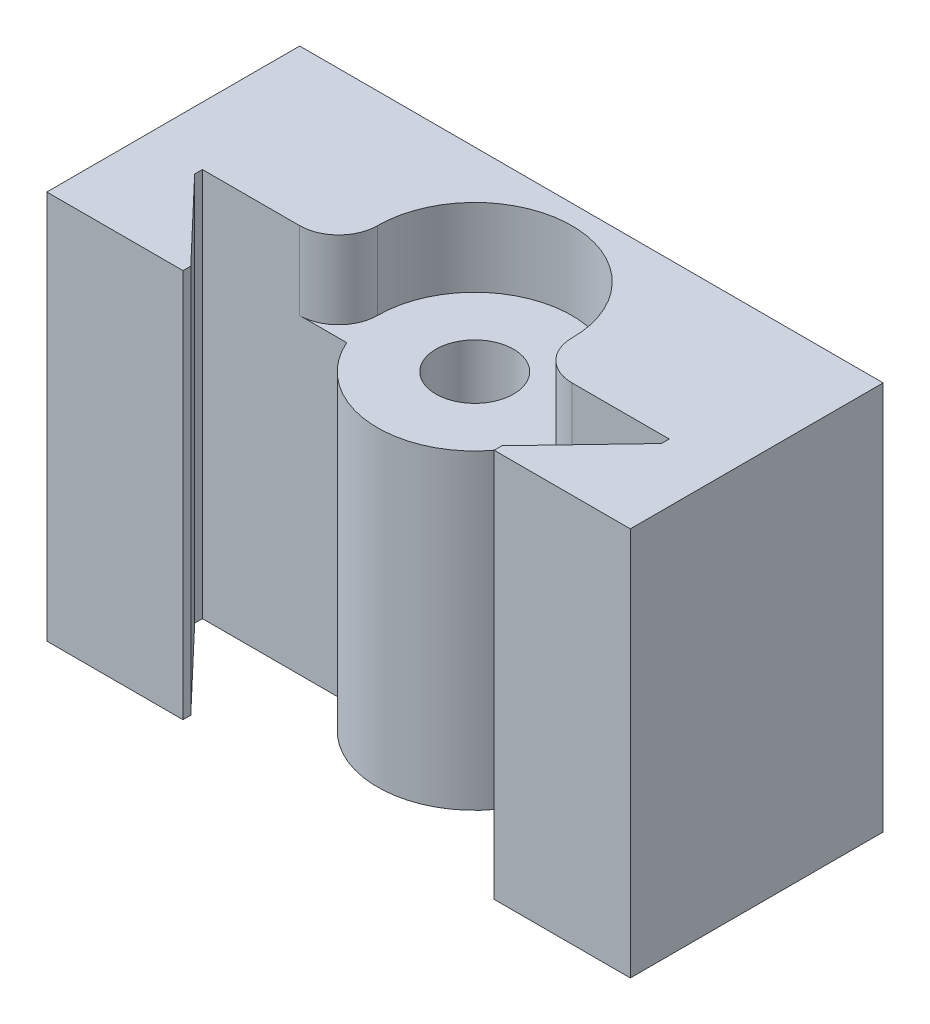
from build123d import *

# Parameters (mm, degrees)
BOSS_EXTRUDE1_DEPTH = 20
SKETCH1_3_R         = 2
BOSS_EXTRUDE2_DEPTH = 16


with BuildPart() as part:
    # Sketch1 → Boss-Extrude1 (new body)
    with BuildSketch(Plane(origin=(0, 0, 0), x_dir=(1, 0, 0), z_dir=(0, 1, 0))):
        with BuildLine():
            Line((-15, 0), (-8, 0))
            Line((-8, 0), (-8, 0.4))
            Line((-8, 0.4), (-12, 4.6))
            Line((-12, 4.6), (-12, 5))
            Line((-12, 5), (-7, 5))
            ThreePointArc((-7, 5), (-5.585786438, 5.585786438), (-5, 7))
            ThreePointArc((-5, 7), (0, 12), (5, 7))
            ThreePointArc((5, 7), (5.585786438, 5.585786438), (7, 5))
            Line((7, 5), (12, 5))
            Line((12, 5), (12, 4.6))
            Line((12, 4.6), (8, 0.4))
            Line((8, 0.4), (8, 0))
            Line((8, 0), (15, 0))
            Line((15, 0), (15, 13))
            Line((15, 13), (-15, 13))
            Line((-15, 13), (-15, 0))
        make_face()
    extrude(amount=BOSS_EXTRUDE1_DEPTH)

    # Sketch1_3 → Boss-Extrude2 (add)
    with BuildSketch(Plane(origin=(0, 0, 0), x_dir=(1, 0, 0), z_dir=(0, 1, 0))):
        with BuildLine():
            ThreePointArc((-4.582575695, 5), (0, 2), (4.582575695, 5))
            Line((4.582575695, 5), (7, 5))
            ThreePointArc((7, 5), (5.585786438, 5.585786438), (5, 7))
            ThreePointArc((5, 7), (0, 12), (-5, 7))
            ThreePointArc((-5, 7), (-5.585786438, 5.585786438), (-7, 5))
            Line((-7, 5), (-4.582575695, 5))
        make_face()
        with Locations((0, 7)):
            Circle(SKETCH1_3_R, mode=Mode.SUBTRACT)
    extrude(amount=BOSS_EXTRUDE2_DEPTH)


solid = part.part
